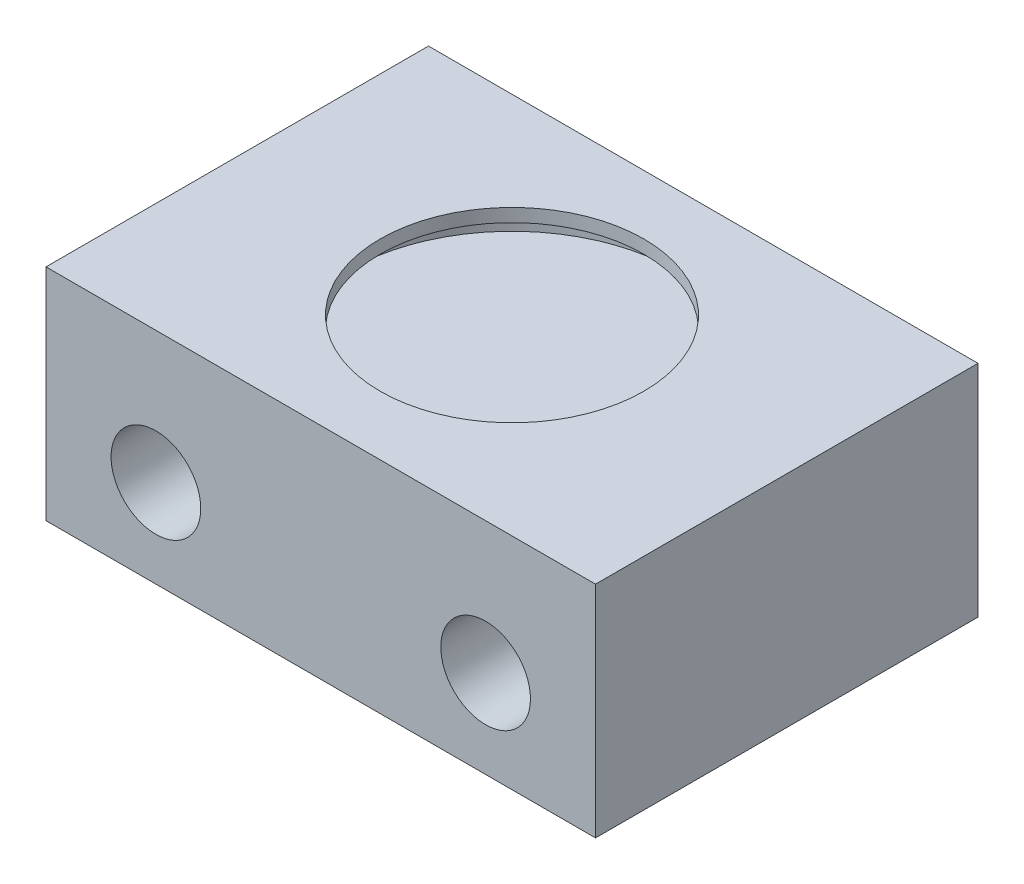
from build123d import *

# Parameters (mm, degrees)
SKETCH1_W                  = 31.75
SKETCH1_H                  = 22.098
BOSS_EXTRUDE1_DEPTH        = 12.7
SKETCH2_R                  = 9.525
CUT_EXTRUDE1_DEPTH         = 1.778
F_6_0_204_DIAMETER_HOLE1_D = 5.1816
CUT_EXTRUDE2_REACH         = 14.7
SKETCH5_R                  = 7.62


with BuildPart() as part:
    # Sketch1 → Boss-Extrude1 (new body)
    with BuildSketch(Plane(origin=(0, 0, 0), x_dir=(1, 0, 0), z_dir=(0, 1, 0))):
        Rectangle(SKETCH1_W, SKETCH1_H)
    extrude(amount=BOSS_EXTRUDE1_DEPTH)

    # Sketch2 → Cut-Extrude1 (cut)
    with BuildSketch(Plane(origin=(0, 10.16, 0), x_dir=(1, 0, 0), z_dir=(0, 1, 0))):
        Circle(SKETCH2_R)
    extrude(amount=CUT_EXTRUDE1_DEPTH, mode=Mode.SUBTRACT)

    # #6 (0.204) Diameter Hole1 (through all)
    with Locations(Plane.XY.offset(11.049)):
        with Locations((-9.525, 5.08), (9.525, 5.08)):
            Hole(F_6_0_204_DIAMETER_HOLE1_D / 2)

    # Sketch5 → Cut-Extrude2 (cut, up to next)
    with BuildSketch(Plane(origin=(0, 12.7, 0), x_dir=(1, 0, 0), z_dir=(0, 1, 0)), mode=Mode.PRIVATE) as cut_extrude2_sk1:
        Circle(SKETCH5_R)
    cut_extrude2_tool1 = extrude(cut_extrude2_sk1.sketch, amount=-CUT_EXTRUDE2_REACH, mode=Mode.PRIVATE) & part.part
    add(cut_extrude2_tool1.solids().sort_by_distance((0, 12.7, 0))[0], mode=Mode.SUBTRACT)


solid = part.part
